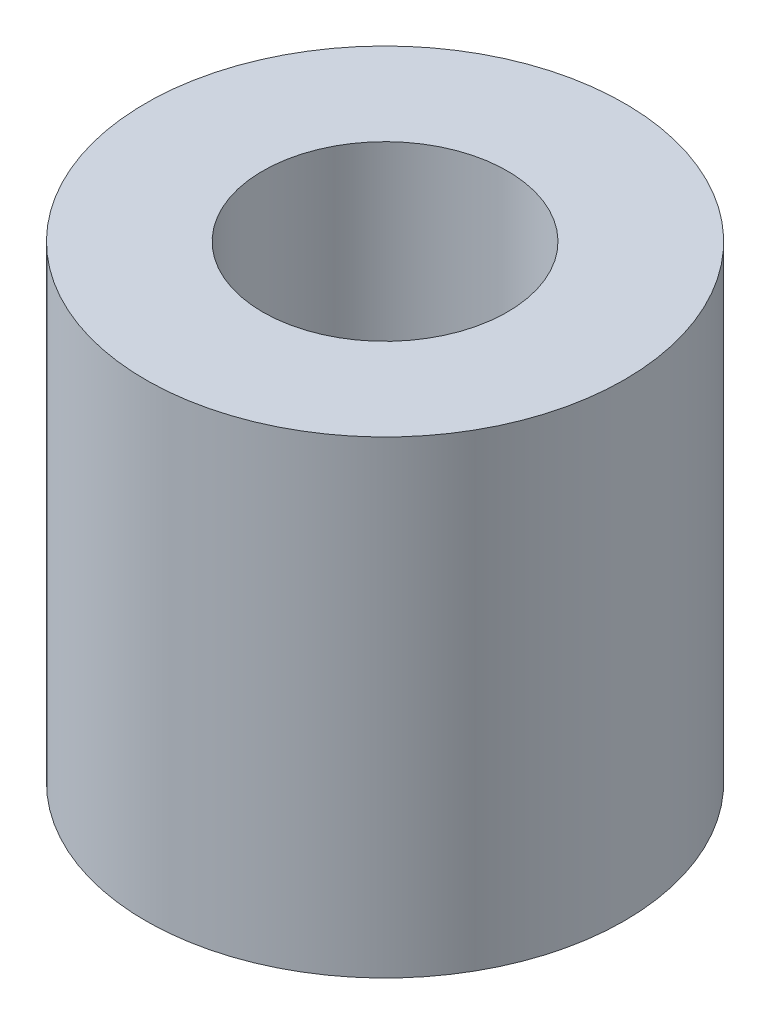
from build123d import *

# Parameters (mm, degrees)
SKETCH1_R           = 5.11
SKETCH1_R_2         = 2.61
EXTRUDE_THIN1_DEPTH = 10


with BuildPart() as part:
    # Sketch1 → Extrude-Thin1 (new body)
    with BuildSketch(Plane(origin=(0, 0, 0), x_dir=(1, 0, 0), z_dir=(0, 1, 0))):
        Circle(SKETCH1_R)
        Circle(SKETCH1_R_2, mode=Mode.SUBTRACT)
    extrude(amount=EXTRUDE_THIN1_DEPTH)


solid = part.part
